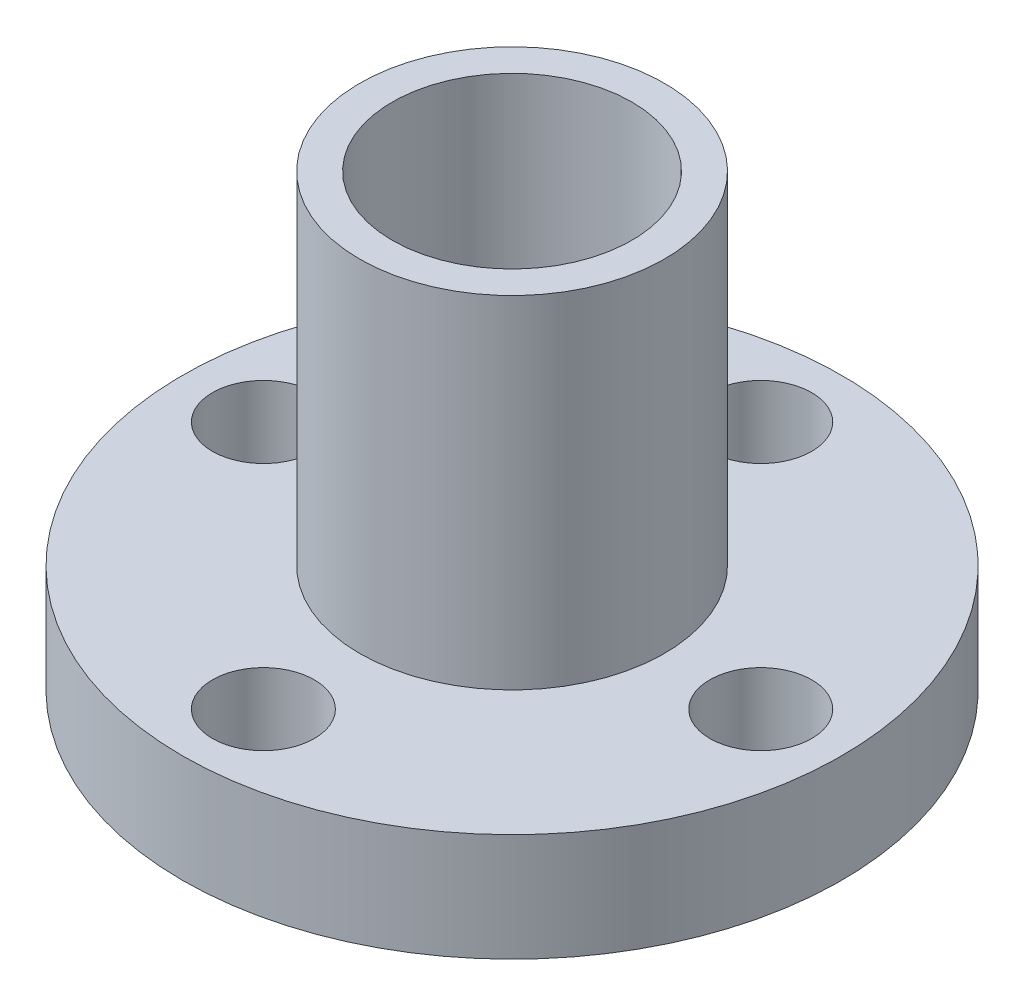
from build123d import *

# Parameters (mm, degrees)
SKETCH1_R           = 11
SKETCH1_R_2         = 5
SKETCH1_R_3         = 1.7
BOSS_EXTRUDE1_DEPTH = 3.6
SKETCH2_R           = 5.085
SKETCH2_R_2         = 4
BOSS_EXTRUDE2_DEPTH = 15


with BuildPart() as part:
    # Sketch1 → Boss-Extrude1 (new body)
    with BuildSketch(Plane(origin=(0, 0, 0), x_dir=(1, 0, 0), z_dir=(0, 1, 0))):
        Circle(SKETCH1_R)
        Circle(SKETCH1_R_2, mode=Mode.SUBTRACT)
        with Locations((-8.3, 0)):
            Circle(SKETCH1_R_3, mode=Mode.SUBTRACT)
        with Locations((0, 8.3)):
            Circle(SKETCH1_R_3, mode=Mode.SUBTRACT)
        with Locations((8.3, 0)):
            Circle(SKETCH1_R_3, mode=Mode.SUBTRACT)
        with Locations((0, -8.3)):
            Circle(SKETCH1_R_3, mode=Mode.SUBTRACT)
    extrude(amount=BOSS_EXTRUDE1_DEPTH)

    # Sketch2 → Boss-Extrude2 (add)
    with BuildSketch(Plane(origin=(0, 0, 0), x_dir=(1, 0, 0), z_dir=(0, 1, 0))):
        Circle(SKETCH2_R)
        Circle(SKETCH2_R_2, mode=Mode.SUBTRACT)
    extrude(amount=BOSS_EXTRUDE2_DEPTH)


solid = part.part
